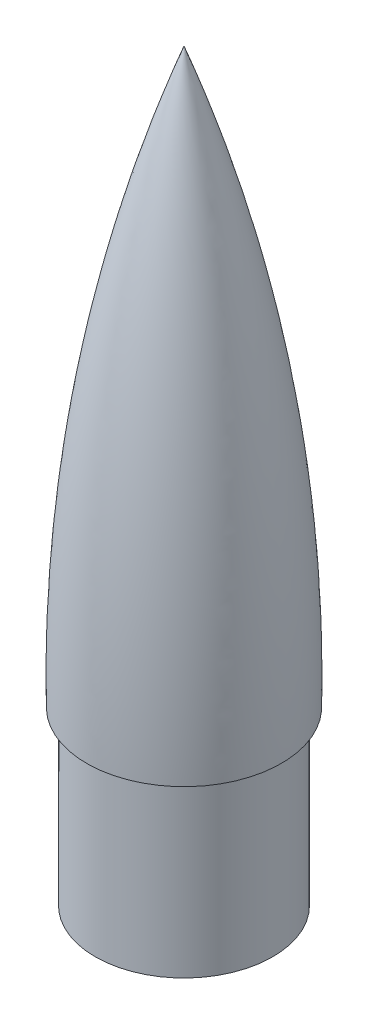
from build123d import *

# Parameters (mm, degrees)
SKETCH_1_R          = 15.5
SKETCH_1_R_2        = 14.5
EXTRUDE_1_DEPTH     = 30
SKETCH_7_R          = 0.8
CUT_EXTRUDE_1_DEPTH = 18.041521301


with BuildPart() as part:
    # Эскиз1 → Бобышка-Вытянуть1 (new body)
    with BuildSketch(Plane(origin=(0, 0, 0), x_dir=(1, 0, 0), z_dir=(0, 1, 0))):
        Circle(SKETCH_1_R)
        Circle(SKETCH_1_R_2, mode=Mode.SUBTRACT)
    extrude(amount=EXTRUDE_1_DEPTH)

    # Эскиз5 → Повернуть1 (revolve)
    with BuildSketch(Plane.XY):
        with BuildLine():
            Line((0, 30), (0, 130))
            ThreePointArc((0, 130), (-13.157936889, 80.791849271), (-17, 30))
            Line((-17, 30), (0, 30))
        make_face()
    revolve(axis=Axis((0, 100, 0), (0, -1, 0)))

    # Эскиз6 → Вырез-Повернуть1 (revolve, cut)
    with BuildSketch(Plane.XY):
        with BuildLine():
            Line((0, 127.5), (0, 30))
            Line((0, 30), (-15, 30))
            add(Edge.make_bspline(
                [(-14.45363087, 41.68986818), (-14.564513424, 36.70975996), (-15, 30)],
                knots=[0, 0, 0, 1, 1, 1], degree=2))
            ThreePointArc((-14.45363087, 41.68986818), (-11.842254072, 73.004469438), (-5.637607077, 103.809110264))
            add(Edge.make_bspline(
                [(0, 127.5), (-1.285260326, 123.677634701), (-2.143778885, 120.771879578), (-5.637607077, 103.809110264)],
                knots=[0, 0, 0, 0, 1, 1, 1, 1], degree=3))
        make_face()
    revolve(axis=Axis((0, 127.5, 0), (0, -1, 0)), mode=Mode.SUBTRACT)

    # Эскиз7 → Вырез-Вытянуть1 (cut, through all)
    with BuildSketch(Plane.XY):
        with Locations((0, 2.5)):
            Circle(SKETCH_7_R)
    extrude(amount=-CUT_EXTRUDE_1_DEPTH, mode=Mode.SUBTRACT)


solid = part.part
